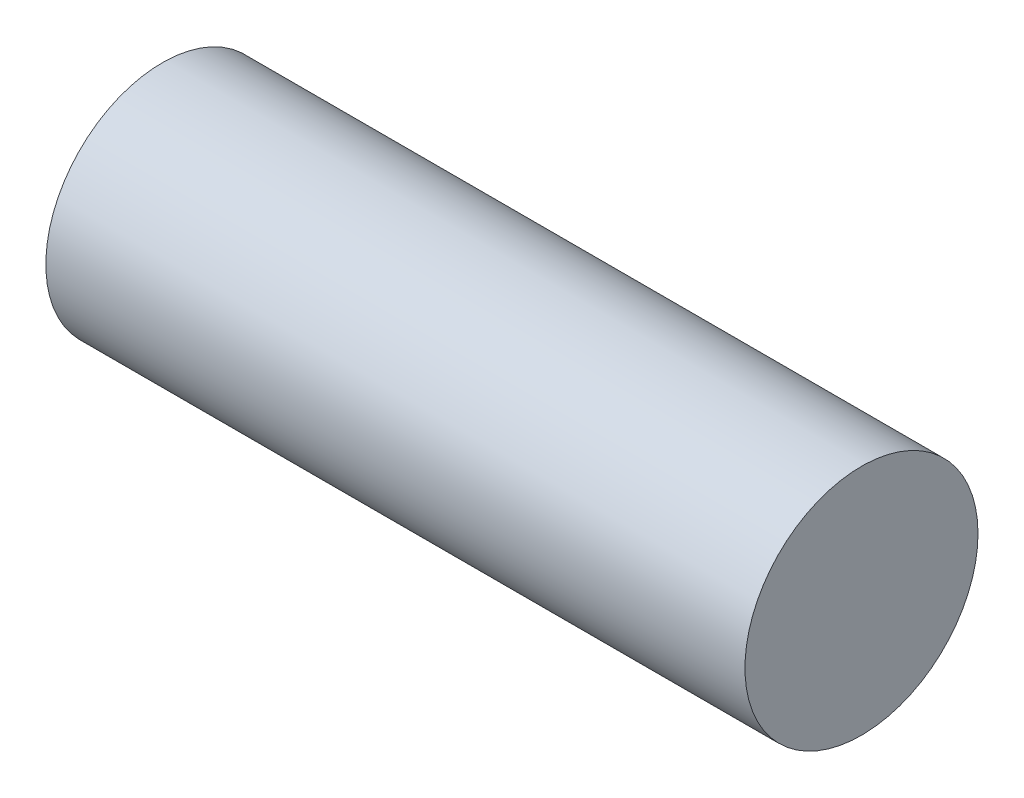
from build123d import *

# Parameters (mm, degrees)
SKETCH1_R           = 15
BOSS_EXTRUDE1_DEPTH = 90


with BuildPart() as part:
    # Sketch1 → Boss-Extrude1 (new body)
    with BuildSketch(Plane(origin=(0, 0, 0), x_dir=(0, 0, -1), z_dir=(1, 0, 0))):
        Circle(SKETCH1_R)
    extrude(amount=BOSS_EXTRUDE1_DEPTH)


solid = part.part
